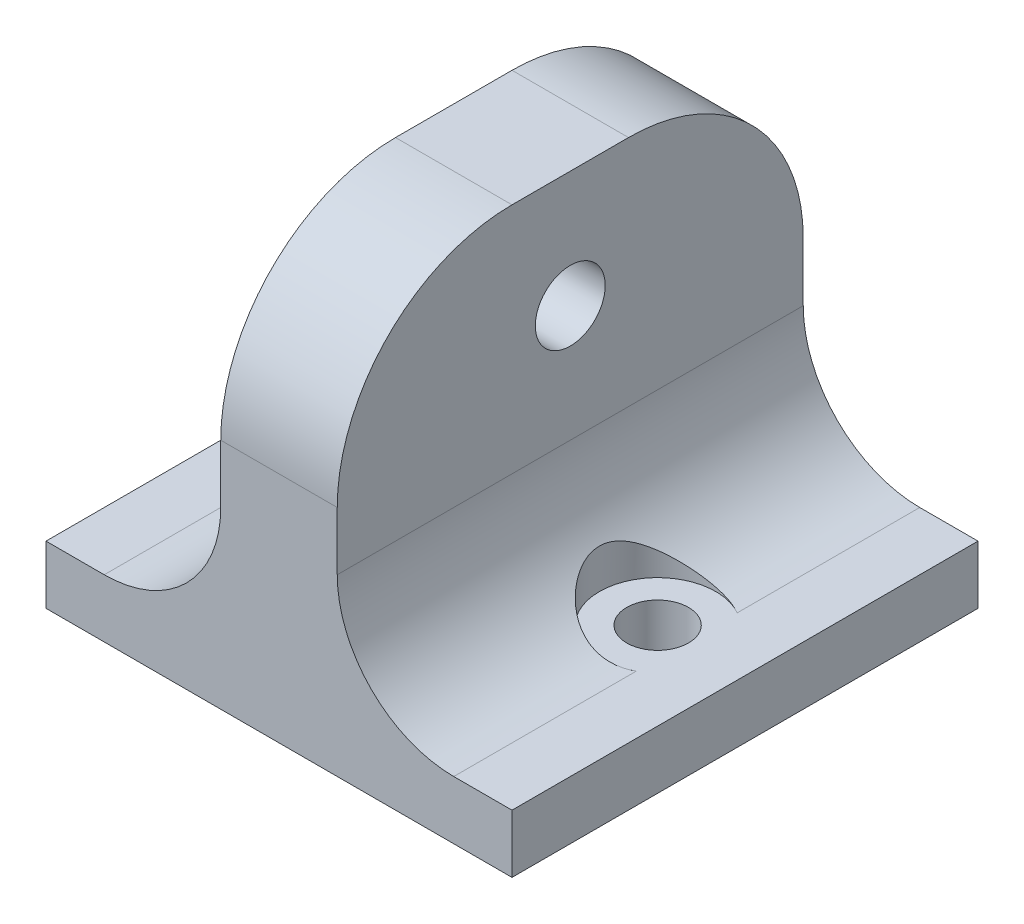
from build123d import *

# Parameters (mm, degrees)
SKETCH1_W                  = 40
SKETCH1_H                  = 40
BOSS_EXTRUDE1_DEPTH        = 5
SKETCH4_W                  = 10
SKETCH4_H                  = 40
BOSS_EXTRUDE3_DEPTH        = 30
SKETCH5_R                  = 3
CUT_EXTRUDE4_DEPTH         = 26
FILLET1_R                  = 15
FILETE1_R                  = 10
ESBO_O1_R                  = 2.65
CORTE_EXTRUS_O1_DEPTH      = 31
CORTE_EXTRUS_O1_DEPTH_BACK = 6
ESBO_O2_R                  = 5
CORTE_EXTRUS_O2_DEPTH      = 31


with BuildPart() as part:
    # Sketch1 → Boss-Extrude1 (new body)
    with BuildSketch(Plane(origin=(0, 0, 0), x_dir=(1, 0, 0), z_dir=(0, 1, 0))):
        Rectangle(SKETCH1_W, SKETCH1_H)
    extrude(amount=BOSS_EXTRUDE1_DEPTH)

    # Sketch4 → Boss-Extrude3 (add)
    with BuildSketch(Plane(origin=(0, 5, 0), x_dir=(1, 0, 0), z_dir=(0, 1, 0))):
        Rectangle(SKETCH4_W, SKETCH4_H)
    extrude(amount=BOSS_EXTRUDE3_DEPTH)

    # Sketch5 → Cut-Extrude4 (cut, through all)
    with BuildSketch(Plane(origin=(5, 0, 0), x_dir=(0, 0, -1), z_dir=(1, 0, 0))):
        with Locations((0, 25)):
            Circle(SKETCH5_R)
    extrude(amount=-CUT_EXTRUDE4_DEPTH, mode=Mode.SUBTRACT)

    # Fillet1
    fillet1_edges = [part.edges().sort_by_distance(p)[0] for p in [
        (0, 35, -20),
        (0, 35, 20),
    ]]
    fillet(fillet1_edges, radius=FILLET1_R)

    # Filete1
    filete1_edges = [part.edges().sort_by_distance(p)[0] for p in [
        (5, 5, 0),
        (-5, 5, 0),
    ]]
    fillet(filete1_edges, radius=FILETE1_R)

    # Esboço1 → Corte-extrusão1 (cut, two sides)
    with BuildSketch(Plane(origin=(0, 5, 0), x_dir=(1, 0, 0), z_dir=(0, 1, 0))) as corte_extrus_o1_sk:
        with Locations((-12.5, 0)):
            Circle(ESBO_O1_R)
        with Locations((12.5, 0)):
            Circle(ESBO_O1_R)
    extrude(amount=CORTE_EXTRUS_O1_DEPTH, mode=Mode.SUBTRACT)
    extrude(corte_extrus_o1_sk.sketch, amount=-CORTE_EXTRUS_O1_DEPTH_BACK, mode=Mode.SUBTRACT)

    # Esboço2 → Corte-extrusão2 (cut, through all)
    with BuildSketch(Plane(origin=(0, 5, 0), x_dir=(1, 0, 0), z_dir=(0, 1, 0))):
        with Locations((-12.5, 0)):
            Circle(ESBO_O2_R)
        with Locations((12.5, 0)):
            Circle(ESBO_O2_R)
    extrude(amount=CORTE_EXTRUS_O2_DEPTH, mode=Mode.SUBTRACT)


solid = part.part
